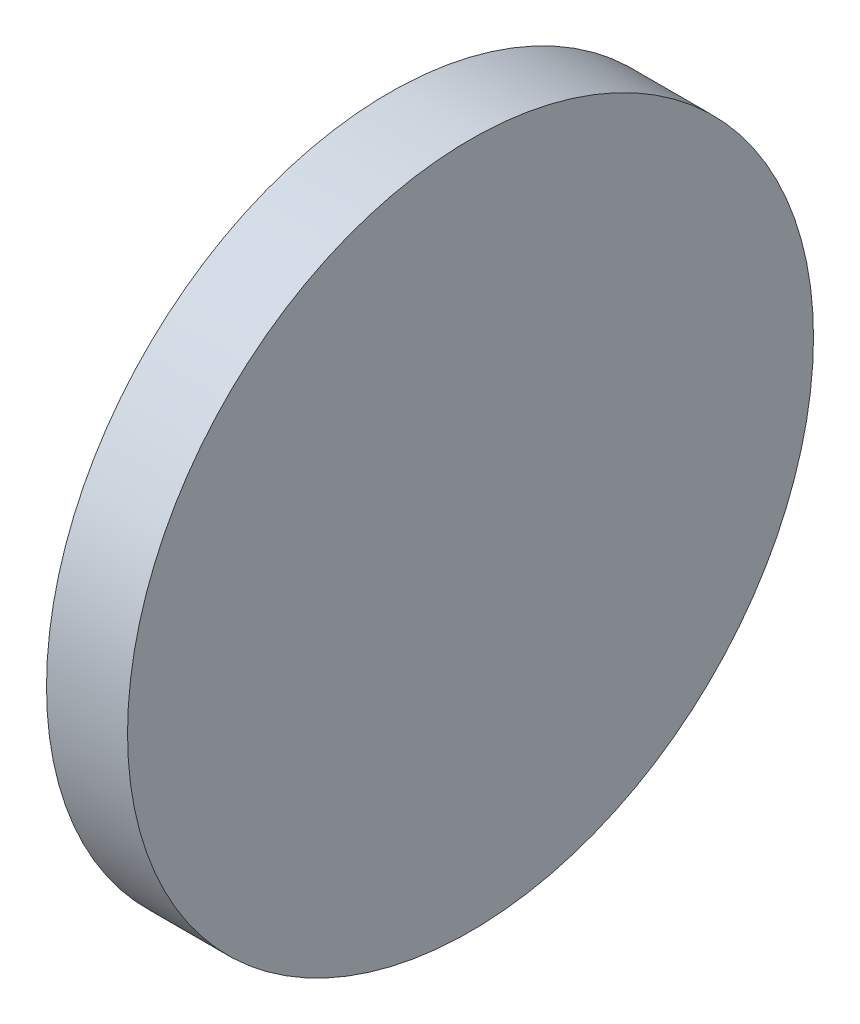
from build123d import *

# Parameters (mm, degrees)
SKETCH_1_W = 6
SKETCH_1_H = 19.05
SKETCH_4_W = 6
SKETCH_4_H = 6.35


with BuildPart() as part:
    # 草图1 → 旋转2 (revolve)
    with BuildSketch(Plane.XY, mode=Mode.PRIVATE) as revolve_2_sk:
        with Locations((0, 9.525)):
            Rectangle(SKETCH_1_W, SKETCH_1_H)
    revolve(revolve_2_sk.sketch.rotate(Axis((-3, 0, 0), (1, 0, 0)), 90), axis=Axis((-3, 0, 0), (1, 0, 0)))  # turned: the seam where the file's is

    # 草图4 → 旋转3 (revolve)
    with BuildSketch(Plane.XY, mode=Mode.PRIVATE) as revolve_3_sk:
        with Locations((0, 22.225)):
            Rectangle(SKETCH_4_W, SKETCH_4_H)
    revolve(revolve_3_sk.sketch.rotate(Axis((-1.614212419, 0, 0), (1, 0, 0)), 90), axis=Axis((-1.614212419, 0, 0), (1, 0, 0)))  # turned: the seam where the file's is


solid = part.part
